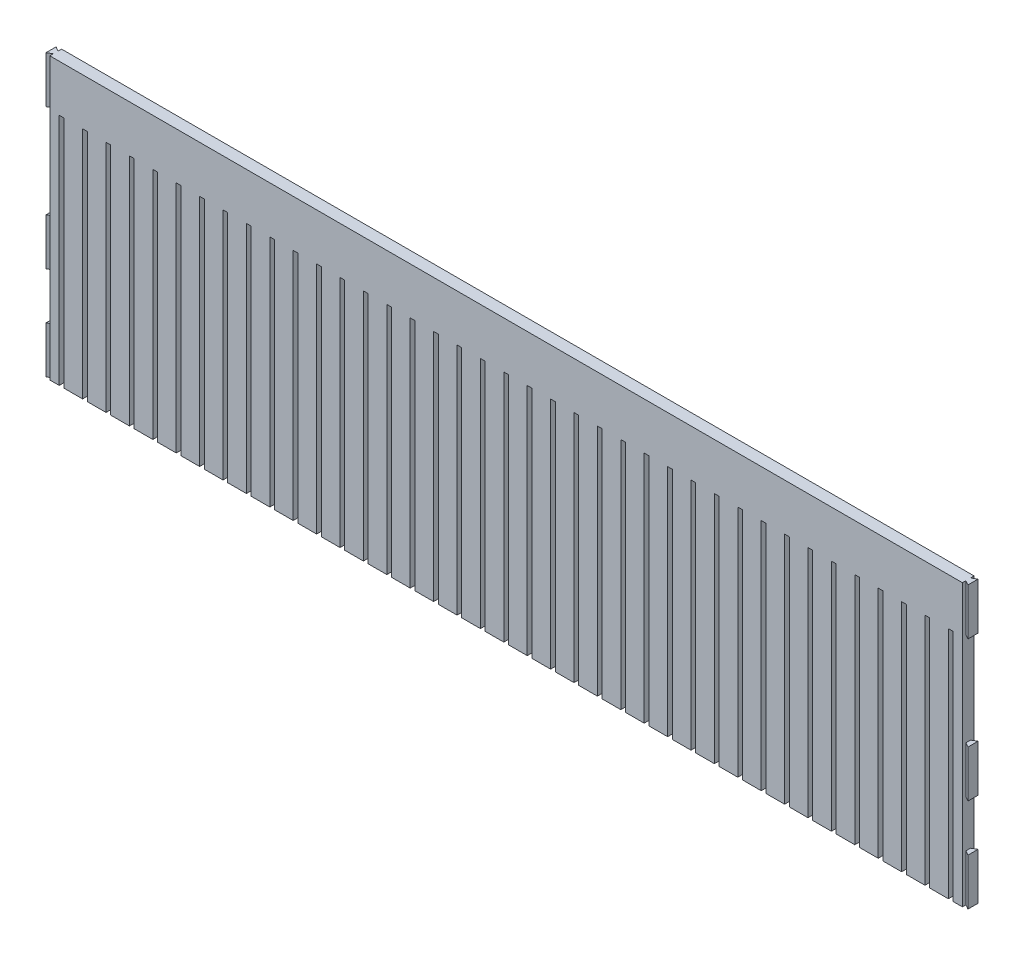
from build123d import *

# Parameters (mm, degrees)
SKETCH_1_W          = 360
SKETCH_1_H          = 80
EXTRUDE_1_DEPTH     = 5
SKETCH_3_W          = 360
SKETCH_3_H          = 5
EXTRUDE_2_DEPTH     = 40
SKETCH_4_W          = 5
SKETCH_4_H          = 120
EXTRUDE_3_DEPTH     = 15
SKETCH_5_W          = 5
SKETCH_5_H          = 120
EXTRUDE_4_DEPTH     = 15
EXTRUDE_5_DEPTH     = 20
EXTRUDE_6_DEPTH     = 20
EXTRUDE_START       = -20
EXTRUDE_7_DEPTH     = 20
SKETCH_9_W          = 2
SKETCH_9_H          = 5
CUT_EXTRUDE_1_DEPTH = 100


with BuildPart() as part:
    # 草图1 → 凸台-拉伸1 (new body)
    with BuildSketch(Plane.XY):
        Rectangle(SKETCH_1_W, SKETCH_1_H)
    extrude(amount=EXTRUDE_1_DEPTH)

    # 草图3 → 凸台-拉伸2 (add)
    with BuildSketch(Plane.XZ.offset(40)):
        with Locations((0, 2.5)):
            Rectangle(SKETCH_3_W, SKETCH_3_H)
    extrude(amount=EXTRUDE_2_DEPTH)

    # 草图4 → 凸台-拉伸3 (add)
    with BuildSketch(Plane.ZY.offset(180)):
        with Locations((2.5, -20)):
            Rectangle(SKETCH_4_W, SKETCH_4_H)
    extrude(amount=EXTRUDE_3_DEPTH)

    # 草图5 → 凸台-拉伸4 (add)
    with BuildSketch(Plane(origin=(180, 0, 0), x_dir=(0, 0, -1), z_dir=(1, 0, 0))):
        with Locations((-2.5, -20)):
            Rectangle(SKETCH_5_W, SKETCH_5_H)
    extrude(amount=EXTRUDE_4_DEPTH)

    # 草图6 → 凸台-拉伸5 (add)
    with BuildSketch(Plane.XZ.offset(80)):
        Polygon((-195, 3.5), (-197, 4.654700538), (-197, 0.345299462), (-195, 1.5), align=None)
        Polygon((195, 1.5), (195, 3.5), (197, 4.654700538), (197, 0.345299462), align=None)
    extrude(amount=-EXTRUDE_5_DEPTH)

    # 草图7 → 凸台-拉伸6 (add)
    with BuildSketch(Plane(origin=(0, 40, 0), x_dir=(1, 0, 0), z_dir=(0, 1, 0))):
        Polygon((-195, -3.5), (-195, -1.5), (-197, -0.345299462), (-197, -4.654700538), align=None)
        Polygon((197, -0.345299462), (195, -1.5), (195, -3.5), (197, -4.654700538), align=None)
    extrude(amount=-EXTRUDE_6_DEPTH)

    # 草图8 → 凸台-拉伸7 (add)
    with BuildSketch(Plane(origin=(0, 0, 0), x_dir=(1, 0, 0), z_dir=(0, 1, 0)).offset(EXTRUDE_START)):
        Polygon((-195, -3.5), (-195, -1.5), (-197, -0.345299462), (-197, -4.654700538), align=None)
        Polygon((197, -0.345299462), (195, -1.5), (195, -3.5), (197, -4.654700538), align=None)
    extrude(amount=-EXTRUDE_7_DEPTH)

    # 草图9 → 切除-拉伸1 (cut)
    with BuildSketch(Plane.XZ.offset(80)):
        with Locations((10, 2.5)):
            Rectangle(SKETCH_9_W, SKETCH_9_H)
        with Locations((20, 2.5)):
            Rectangle(SKETCH_9_W, SKETCH_9_H)
        with Locations((0, 2.5)):
            Rectangle(SKETCH_9_W, SKETCH_9_H)
        with Locations((30, 2.5)):
            Rectangle(SKETCH_9_W, SKETCH_9_H)
        with Locations((40, 2.5)):
            Rectangle(SKETCH_9_W, SKETCH_9_H)
        with Locations((50, 2.5)):
            Rectangle(SKETCH_9_W, SKETCH_9_H)
        with Locations((60, 2.5)):
            Rectangle(SKETCH_9_W, SKETCH_9_H)
        with Locations((70, 2.5)):
            Rectangle(SKETCH_9_W, SKETCH_9_H)
        with Locations((80, 2.5)):
            Rectangle(SKETCH_9_W, SKETCH_9_H)
        with Locations((90, 2.5)):
            Rectangle(SKETCH_9_W, SKETCH_9_H)
        with Locations((100, 2.5)):
            Rectangle(SKETCH_9_W, SKETCH_9_H)
        with Locations((110, 2.5)):
            Rectangle(SKETCH_9_W, SKETCH_9_H)
        with Locations((120, 2.5)):
            Rectangle(SKETCH_9_W, SKETCH_9_H)
        with Locations((130, 2.5)):
            Rectangle(SKETCH_9_W, SKETCH_9_H)
        with Locations((140, 2.5)):
            Rectangle(SKETCH_9_W, SKETCH_9_H)
        with Locations((150, 2.5)):
            Rectangle(SKETCH_9_W, SKETCH_9_H)
        with Locations((160, 2.5)):
            Rectangle(SKETCH_9_W, SKETCH_9_H)
        with Locations((170, 2.5)):
            Rectangle(SKETCH_9_W, SKETCH_9_H)
        with Locations((180, 2.5)):
            Rectangle(SKETCH_9_W, SKETCH_9_H)
        with Locations((190, 2.5)):
            Rectangle(SKETCH_9_W, SKETCH_9_H)
        with Locations((-10, 2.5)):
            Rectangle(SKETCH_9_W, SKETCH_9_H)
        with Locations((-20, 2.5)):
            Rectangle(SKETCH_9_W, SKETCH_9_H)
        with Locations((-30, 2.5)):
            Rectangle(SKETCH_9_W, SKETCH_9_H)
        with Locations((-40, 2.5)):
            Rectangle(SKETCH_9_W, SKETCH_9_H)
        with Locations((-50, 2.5)):
            Rectangle(SKETCH_9_W, SKETCH_9_H)
        with Locations((-60, 2.5)):
            Rectangle(SKETCH_9_W, SKETCH_9_H)
        with Locations((-70, 2.5)):
            Rectangle(SKETCH_9_W, SKETCH_9_H)
        with Locations((-80, 2.5)):
            Rectangle(SKETCH_9_W, SKETCH_9_H)
        with Locations((-90, 2.5)):
            Rectangle(SKETCH_9_W, SKETCH_9_H)
        with Locations((-100, 2.5)):
            Rectangle(SKETCH_9_W, SKETCH_9_H)
        with Locations((-110, 2.5)):
            Rectangle(SKETCH_9_W, SKETCH_9_H)
        with Locations((-120, 2.5)):
            Rectangle(SKETCH_9_W, SKETCH_9_H)
        with Locations((-130, 2.5)):
            Rectangle(SKETCH_9_W, SKETCH_9_H)
        with Locations((-140, 2.5)):
            Rectangle(SKETCH_9_W, SKETCH_9_H)
        with Locations((-150, 2.5)):
            Rectangle(SKETCH_9_W, SKETCH_9_H)
        with Locations((-160, 2.5)):
            Rectangle(SKETCH_9_W, SKETCH_9_H)
        with Locations((-170, 2.5)):
            Rectangle(SKETCH_9_W, SKETCH_9_H)
        with Locations((-180, 2.5)):
            Rectangle(SKETCH_9_W, SKETCH_9_H)
        with Locations((-190, 2.5)):
            Rectangle(SKETCH_9_W, SKETCH_9_H)
    extrude(amount=-CUT_EXTRUDE_1_DEPTH, mode=Mode.SUBTRACT)


solid = part.part
